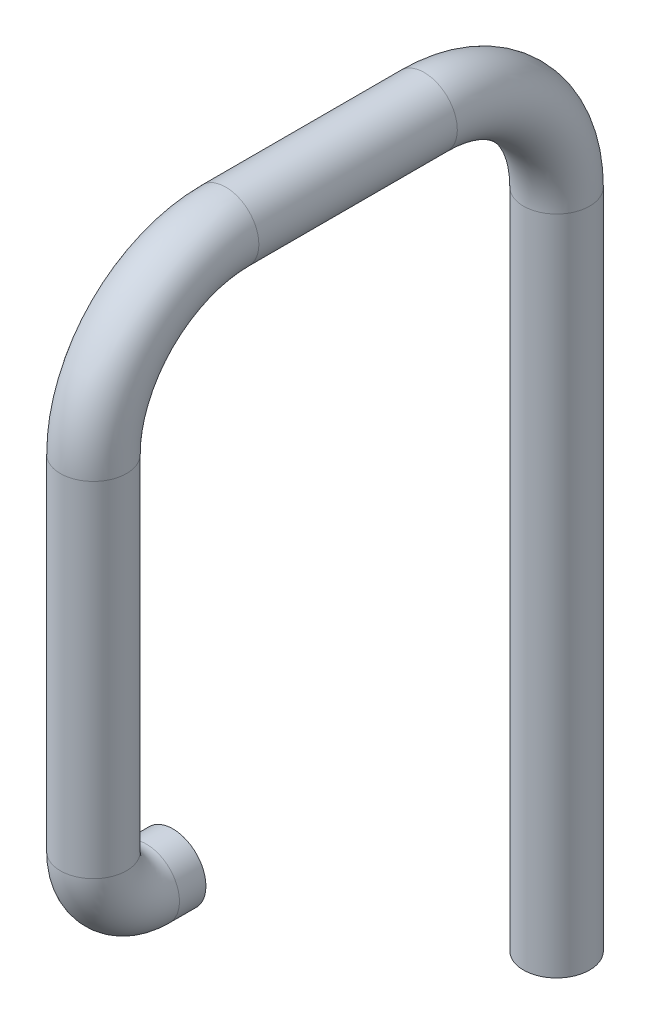
from build123d import *

# Parameters (mm, degrees)
SKETCH2_R = 2.5


with BuildPart() as part:
    # Sweep1: sweep along a path in Sketch1
    with BuildLine(Plane(origin=(0, 0, 0), x_dir=(0, 0, -1), z_dir=(1, 0, 0))) as sweep1_path:
        Line((0, 0), (-2, 0))
        ThreePointArc((-2, 0), (-4.828427125, 1.171572875), (-6, 4))
        Line((-6, 4), (-6, 30))
        ThreePointArc((-6, 30), (-3.071067812, 37.071067812), (4, 40))
        Line((4, 40), (19, 40))
        ThreePointArc((19, 40), (26.071067812, 37.071067812), (29, 30))
        Line((29, 30), (29, -20))
    # Sketch2 → Sweep1 (sweep)
    with BuildSketch(Plane.XY):
        Circle(SKETCH2_R)
    sweep(path=sweep1_path.line)


solid = part.part
